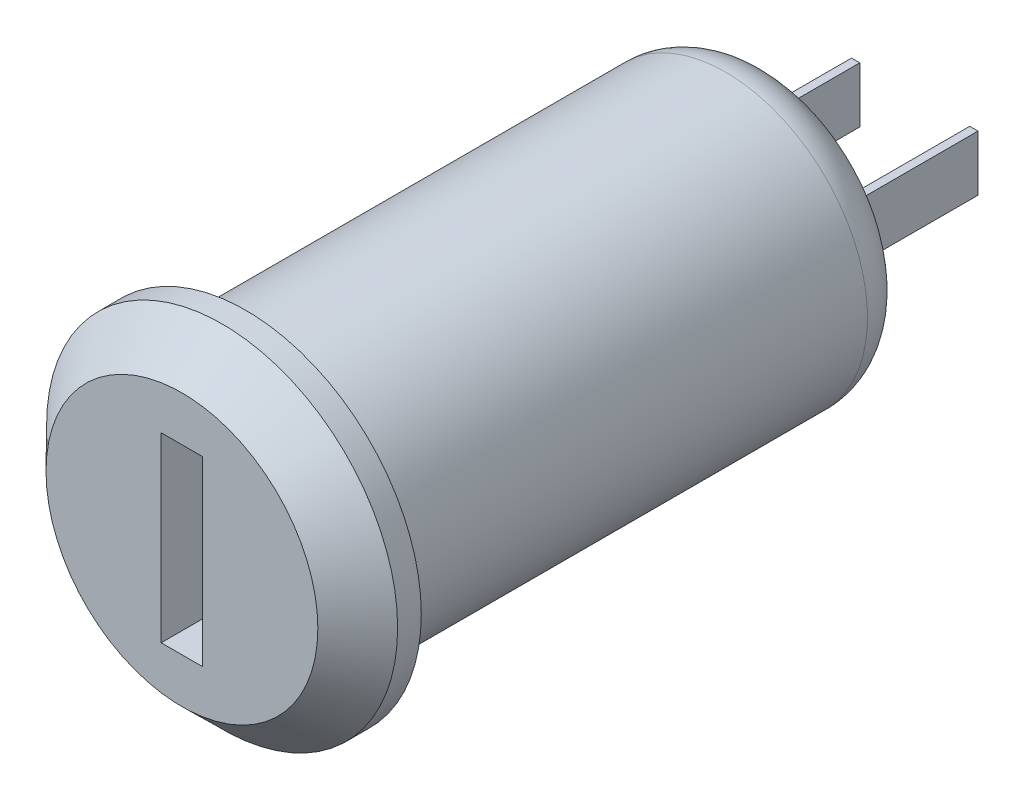
from build123d import *

# Parameters (mm, degrees)
SKETCH2_W           = 1.754577672
SKETCH2_H           = 7.693148258
CUT_EXTRUDE1_DEPTH  = 10
SKETCH3_W           = 0.35
SKETCH3_H           = 2.35
BOSS_EXTRUDE1_DEPTH = 6
FILLET1_R           = 2


with BuildPart() as part:
    # Sketch1 → Revolve1 (revolve)
    with BuildSketch(Plane(origin=(0, 0, 0), x_dir=(1, 0, 0), z_dir=(0, 1, 0))):
        Polygon((-7.425, -2.233468586), (-5.75, -3.933468586), (0, -3.933468586), (0, 0), (0, 21.066531414), (-6, 21.066531414), (-6, -1.233468586), (-7.425, -1.233468586), align=None)
    revolve(axis=Axis((0, 0, -16.306049865), (0, 0, 1)))

    # Sketch2 → Cut-Extrude1 (cut)
    with BuildSketch(Plane.XY.offset(3.933468586)):
        Rectangle(SKETCH2_W, SKETCH2_H)
    extrude(amount=-CUT_EXTRUDE1_DEPTH, mode=Mode.SUBTRACT)

    # Sketch3 → Boss-Extrude1 (add)
    with BuildSketch(Plane(origin=(0, 0, -21.066531414), x_dir=(-1, 0, 0), z_dir=(0, 0, -1))):
        with Locations((-2.5, 0)):
            Rectangle(SKETCH3_W, SKETCH3_H)
        with Locations((2.5, 0)):
            Rectangle(SKETCH3_W, SKETCH3_H)
    extrude(amount=BOSS_EXTRUDE1_DEPTH)

    # Fillet1
    fillet1_edges = [part.edges().sort_by_distance(p)[0] for p in [
        (6, 0, -21.066531414),
    ]]
    fillet(fillet1_edges, radius=FILLET1_R)


solid = part.part
